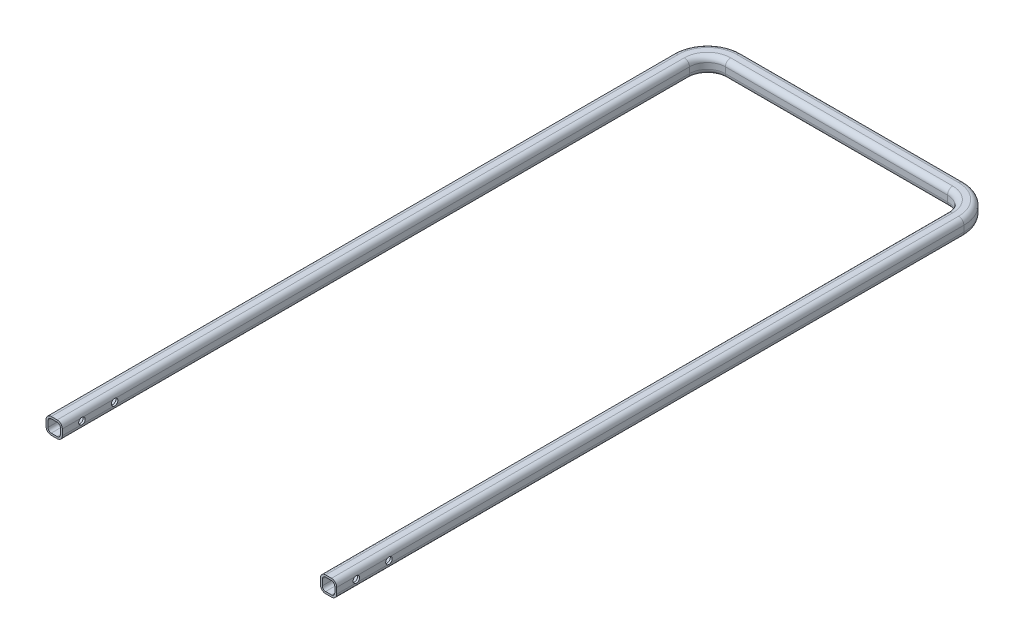
from build123d import *

# Parameters (mm, degrees)
SKETCH4_R               = 5
CUT_EXTRUDE2_DEPTH      = 433.5000001
CUT_EXTRUDE2_DEPTH_BACK = 13.5000001


with BuildPart() as part:
    # Sweep-Thin1: sweep along a path in Sketch1
    with BuildLine(Plane(origin=(0, 0, 0), x_dir=(1, 0, 0), z_dir=(0, 1, 0))) as sweep_thin1_path:
        Line((0, 0), (0, 960))
        ThreePointArc((0, 960), (11.715728753, 988.284271247), (40, 1000))
        Line((40, 1000), (380, 1000))
        ThreePointArc((380, 1000), (408.284271247, 988.284271247), (420, 960))
        Line((420, 960), (420, 0))
    # Sketch3 → Sweep-Thin1 (sweep)
    with BuildSketch(Plane.XY):
        with BuildLine():
            Line((4.5, 12.5), (-4.5, 12.5))
            ThreePointArc((-4.5, 12.5), (-10.156854249, 10.156854249), (-12.5, 4.5))
            Line((-12.5, 4.5), (-12.5, -4.5))
            ThreePointArc((-12.5, -4.5), (-10.156854249, -10.156854249), (-4.5, -12.5))
            Line((-4.5, -12.5), (4.5, -12.5))
            ThreePointArc((4.5, -12.5), (10.156854249, -10.156854249), (12.5, -4.5))
            Line((12.5, -4.5), (12.5, 4.5))
            ThreePointArc((12.5, 4.5), (10.156854249, 10.156854249), (4.5, 12.5))
        make_face()
        with BuildLine():
            Line((4.5, 9.5), (-4.5, 9.5))
            ThreePointArc((-4.5, 9.5), (-8.035533906, 8.035533906), (-9.5, 4.5))
            Line((-9.5, 4.5), (-9.5, -4.5))
            ThreePointArc((-9.5, -4.5), (-8.035533906, -8.035533906), (-4.5, -9.5))
            Line((-4.5, -9.5), (4.5, -9.5))
            ThreePointArc((4.5, -9.5), (8.035533906, -8.035533906), (9.5, -4.5))
            Line((9.5, -4.5), (9.5, 4.5))
            ThreePointArc((9.5, 4.5), (8.035533906, 8.035533906), (4.5, 9.5))
        make_face(mode=Mode.SUBTRACT)
    sweep(path=sweep_thin1_path.line)

    # Sketch4 → Cut-Extrude2 (cut, two sides)
    with BuildSketch(Plane(origin=(0, 0, 0), x_dir=(0, 0, -1), z_dir=(1, 0, 0))) as cut_extrude2_sk:
        with Locations((30, 0)):
            Circle(SKETCH4_R)
        with Locations((80, 0)):
            Circle(SKETCH4_R)
    extrude(amount=CUT_EXTRUDE2_DEPTH, mode=Mode.SUBTRACT)
    extrude(cut_extrude2_sk.sketch, amount=-CUT_EXTRUDE2_DEPTH_BACK, mode=Mode.SUBTRACT)


solid = part.part
